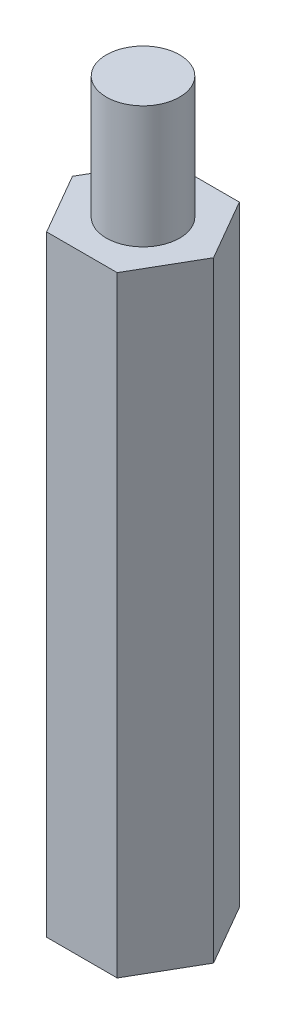
from build123d import *

# Parameters (mm, degrees)
EXTRUDE_1_DEPTH     = 25
SKETCH_2_R          = 1.5
EXTRUDE_2_DEPTH     = 5
SKETCH_3_R          = 1.5
CUT_EXTRUDE_1_DEPTH = 5


with BuildPart() as part:
    # 草圖1 → 填料-伸長1 (new body)
    with BuildSketch(Plane(origin=(0, 0, 0), x_dir=(1, 0, 0), z_dir=(0, 1, 0))):
        Polygon((2.886751346, 0), (1.443375673, 2.5), (-1.443375673, 2.5), (-2.886751346, 0), (-1.443375673, -2.5), (1.443375673, -2.5), align=None)
    extrude(amount=EXTRUDE_1_DEPTH)

    # 草圖2 → 填料-伸長2 (add)
    with BuildSketch(Plane(origin=(0, 25, 0), x_dir=(1, 0, 0), z_dir=(0, 1, 0))):
        Circle(SKETCH_2_R)
    extrude(amount=EXTRUDE_2_DEPTH)

    # 草圖3 → 除料-伸長1 (cut)
    with BuildSketch(Plane.XZ):
        Circle(SKETCH_3_R)
    extrude(amount=-CUT_EXTRUDE_1_DEPTH, mode=Mode.SUBTRACT)


solid = part.part
